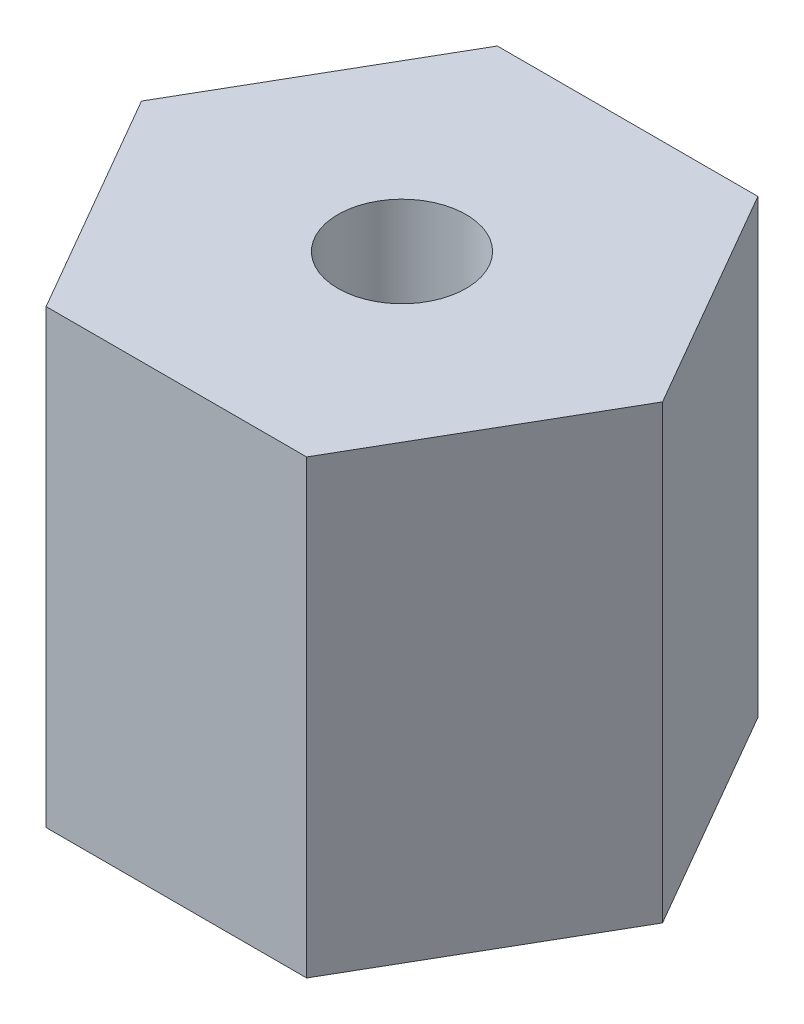
from build123d import *

# Parameters (mm, degrees)
BOSS_EXTRUDE1_DEPTH   = 9.525
F_6_32_TAPPED_HOLE1_D = 2.7051


with BuildPart() as part:
    # Sketch1 → Boss-Extrude1 (new body)
    with BuildSketch(Plane(origin=(0, 0, 0), x_dir=(1, 0, 0), z_dir=(0, 1, 0))):
        Polygon((5.499261314, 0), (2.749630657, 4.7625), (-2.749630657, 4.7625), (-5.499261314, 0), (-2.749630657, -4.7625), (2.749630657, -4.7625), align=None)
    extrude(amount=BOSS_EXTRUDE1_DEPTH)

    # #6-32 Tapped Hole1 (through all)
    with Locations(Plane(origin=(0, 9.525, 0), x_dir=(1, 0, 0), z_dir=(0, 1, 0))):
        with Locations((0, 0)):
            Hole(F_6_32_TAPPED_HOLE1_D / 2)


solid = part.part
